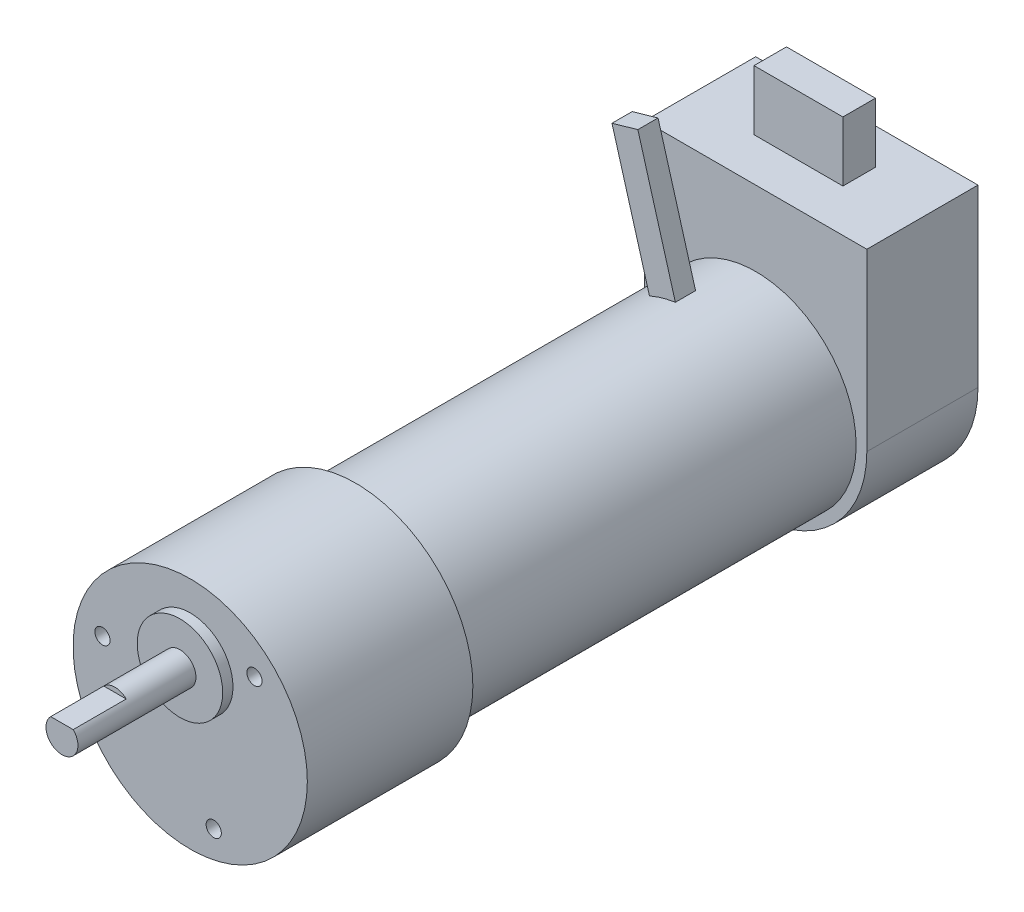
from build123d import *

# Parameters (mm, degrees)
BOSS_EXTRUDE1_DEPTH = 16.51
SKETCH4_W           = 4.826
SKETCH4_H           = 8.89
BOSS_EXTRUDE2_DEPTH = 6.604
CUT_EXTRUDE1_DEPTH  = 7.874
CIRPATTERN1_COUNT   = 3
BOSS_EXTRUDE3_START = -23.29
BOSS_EXTRUDE3_DEPTH = 3


with BuildPart() as part:
    # Sketch1 → Revolve1 (revolve)
    with BuildSketch(Plane(origin=(0, 0, 0), x_dir=(0, 0, -1), z_dir=(1, 0, 0))):
        Polygon((0, 0), (0, 17.399), (24.5872, 17.399), (24.5872, 14.9225), (83.9978, 14.9225), (83.9978, 0), align=None)
    revolve(axis=Axis((0, 0, 55), (0, 0, -1)))

    # Sketch3 → Boss-Extrude1 (add)
    with BuildSketch(Plane(origin=(0, 0, -83.9978), x_dir=(-1, 0, 0), z_dir=(0, 0, -1))):
        with BuildLine():
            Line((-16.51, 0), (-16.51, 26.035))
            Line((-16.51, 26.035), (16.51, 26.035))
            Line((16.51, 26.035), (16.51, 0))
            ThreePointArc((16.51, 0), (0, -16.51), (-16.51, 0))
        make_face()
    extrude(amount=BOSS_EXTRUDE1_DEPTH)

    # Sketch4 → Boss-Extrude2 (add, symmetric)
    with BuildSketch(Plane(origin=(0, 0, 0), x_dir=(0, 0, -1), z_dir=(1, 0, 0))):
        with Locations((92.7608, 30.48)):
            Rectangle(SKETCH4_W, SKETCH4_H)
    extrude(amount=BOSS_EXTRUDE2_DEPTH, both=True)

    # Sketch5 → Revolve2 (revolve)
    with BuildSketch(Plane(origin=(0, 0, 0), x_dir=(0, 0, -1), z_dir=(1, 0, 0))):
        Polygon((0, 13.0048), (-1.524, 13.0048), (-1.524, 9.0297), (-19.05, 9.0297), (-19.05, 6.6548), (0, 6.6548), align=None)
    revolve(axis=Axis((0, 6.6548, 5.02539), (0, 0, -1)))

    # Sketch6 → Cut-Extrude1 (cut)
    with BuildSketch(Plane.XY.offset(19.05)):
        with BuildLine():
            Line((-1.669458355, 8.3439), (1.669458355, 8.3439))
            ThreePointArc((1.669458355, 8.3439), (0, 9.0297), (-1.669458355, 8.3439))
        make_face()
    extrude(amount=-CUT_EXTRUDE1_DEPTH, mode=Mode.SUBTRACT)

    # Sketch7 → #4-40 Tapped Hole1 (revolve, cut)
    with BuildSketch(Plane(origin=(3.49243949, -13.033961618, 0), x_dir=(0, -1, 0), z_dir=(1, 0, 0))):
        Polygon((0, 0), (0, 7.409152758), (1.1303, 6.73), (1.1303, 0), align=None)
    f_4_40_tapped_hole1 = revolve(axis=Axis((3.49243949, -13.033961618, 6.35), (0, 0, -1)), mode=Mode.SUBTRACT)

    # CirPattern1: #4-40 Tapped Hole1 ×3 about axis
    cirpattern1_axis = Axis((0, 0, 0), (0, 0, 1))
    for i in range(1, CIRPATTERN1_COUNT):
        add(f_4_40_tapped_hole1.rotate(cirpattern1_axis, i * 360 / CIRPATTERN1_COUNT), mode=Mode.SUBTRACT)

    # Sketch9 → Boss-Extrude3 (add)
    with BuildSketch(Plane(origin=(0, 0, -100.5078), x_dir=(-1, 0, 0), z_dir=(0, 0, -1)).offset(BOSS_EXTRUDE3_START)):
        Polygon((0, 0), (-1.922523392, 0.551274712), (7.724784062, 34.195434069), (11.569830845, 33.092884646), (1.922523392, -0.551274712), align=None)
    extrude(amount=-BOSS_EXTRUDE3_DEPTH)


solid = part.part
